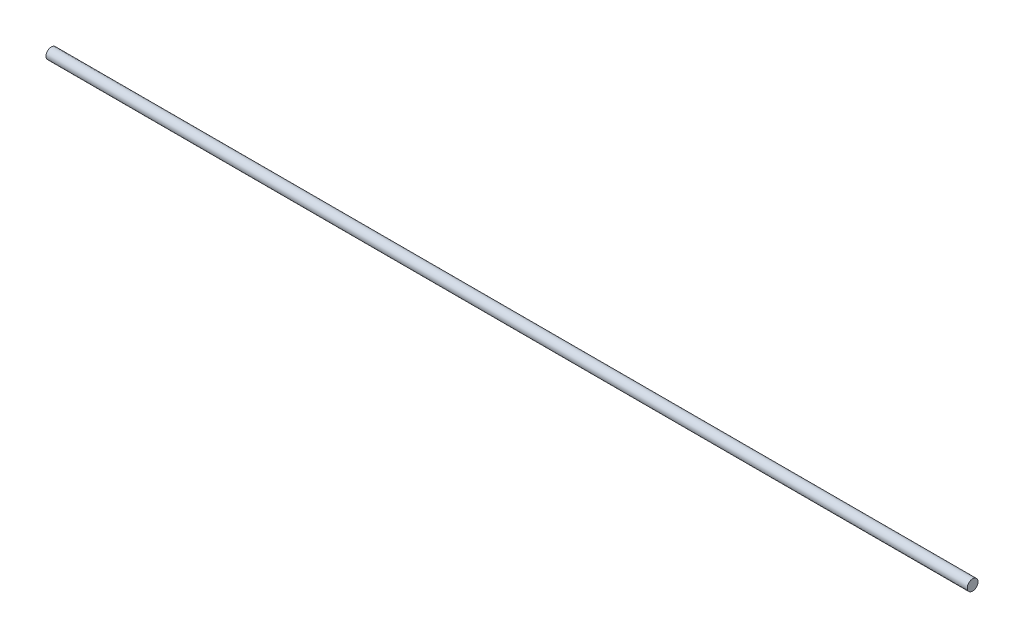
from build123d import *

# Parameters (mm, degrees)
SKETCH1_R           = 1.778
BOSS_EXTRUDE1_DEPTH = 152.4


with BuildPart() as part:
    # Sketch1 → Boss-Extrude1 (new body, symmetric)
    with BuildSketch(Plane(origin=(0, 0, 0), x_dir=(0, 0, -1), z_dir=(1, 0, 0))):
        Circle(SKETCH1_R)
    extrude(amount=BOSS_EXTRUDE1_DEPTH, both=True)


solid = part.part
